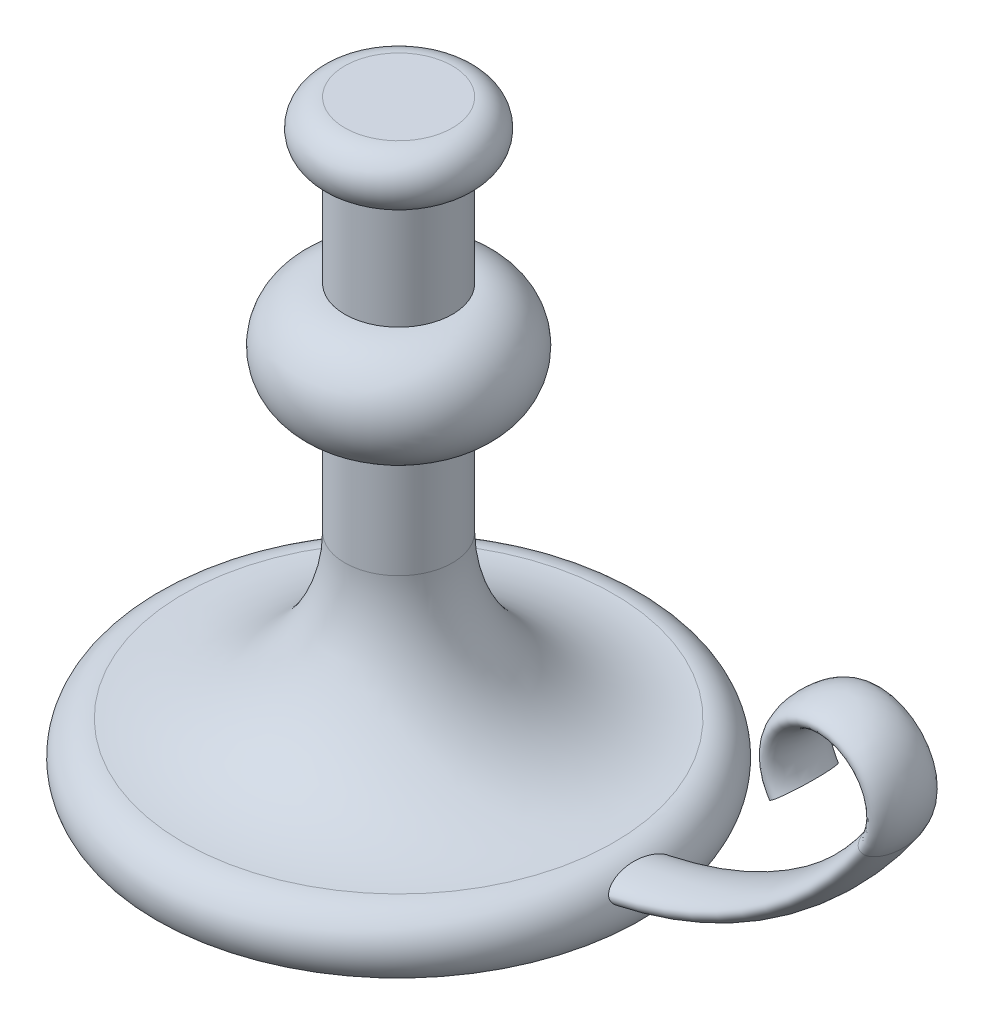
from build123d import *

# Parameters (mm, degrees)
SKETCH3_RX = 12.10799865
SKETCH3_RY = 5


with BuildPart() as part:
    # Sketch1 → Revolve1 (revolve)
    with BuildSketch(Plane.XY):
        with BuildLine():
            Line((0, 0), (0, 220))
            Line((0, 220), (20, 220))
            ThreePointArc((20, 220), (30, 210), (20, 200))
            Line((20, 200), (20, 160))
            ThreePointArc((20, 160), (40, 140), (20, 120))
            Line((20, 120), (20, 80))
            ThreePointArc((20, 80), (37.573593129, 37.573593129), (80, 20))
            ThreePointArc((80, 20), (91.180339887, 13.090169944), (90, 0))
            Line((90, 0), (0, 0))
        make_face()
    revolve(axis=Axis((0, 301.661898631, 0), (0, -1, 0)))

    # Sweep1: sweep along a path in Sketch2
    with BuildLine(Plane.XY) as sweep1_path:
        Line((0, 10), (60, 10))
        ThreePointArc((60, 10), (129.821200219, 27.240819526), (183.592070943, 75))
        ThreePointArc((183.592070943, 75), (167.113128151, 106.333333333), (150.634185358, 75))
    # Sketch3 → Sweep1 (sweep)
    with BuildSketch(Plane(origin=(0, 0, 0), x_dir=(0, 0, -1), z_dir=(1, 0, 0))):
        with Locations((0, 10)):
            Ellipse(SKETCH3_RX, SKETCH3_RY)
    sweep(path=sweep1_path.line)


solid = part.part
